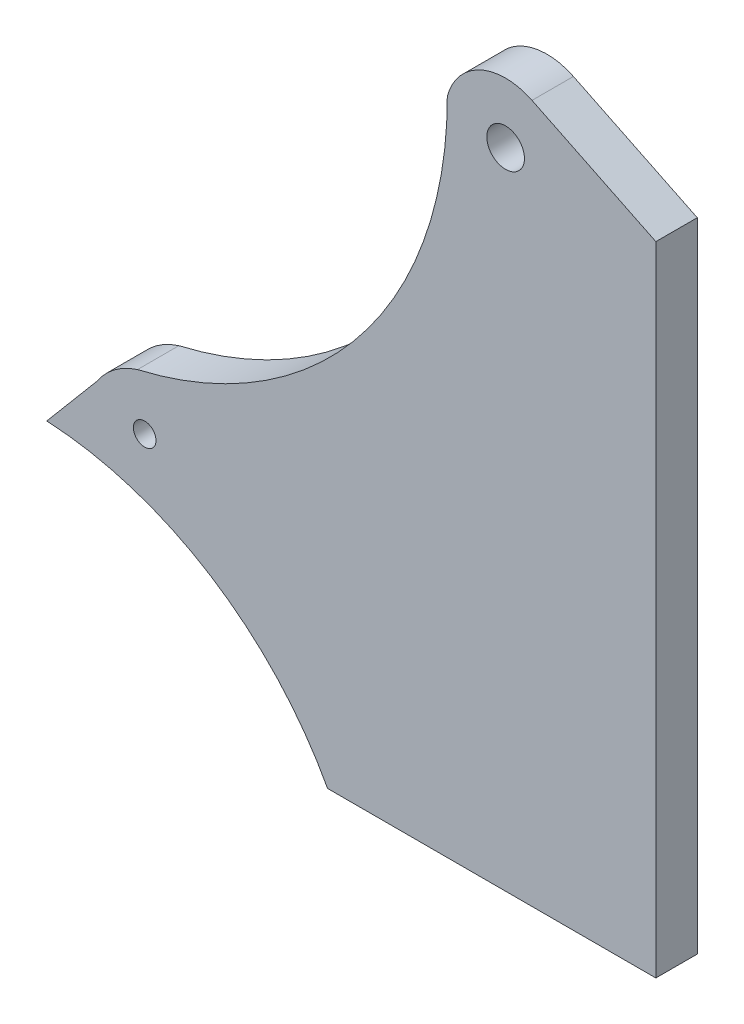
from build123d import *

# Parameters (mm, degrees)
SKETCH1_R           = 25
SKETCH1_R_2         = 15
BOSS_EXTRUDE1_DEPTH = 55


with BuildPart() as part:
    # Sketch1 → Boss-Extrude1 (new body)
    with BuildSketch(Plane.XY):
        with BuildLine():
            Line((0, 0), (436, 0))
            Line((436, 0), (436, 847))
            Line((436, 847), (271.520689527, 927.221919862))
            ThreePointArc((271.520689527, 927.221919862), (202.977427959, 927.978702538), (159.009788885, 875.389747989))
            ThreePointArc((159.009788885, 875.389747989), (44.140964675, 543.56321378), (-252.456286899, 355.590433997))
            ThreePointArc((-252.456286899, 355.590433997), (-283.190978989, 339.913558022), (-306.768623817, 314.724663594))
            Line((-306.768623817, 314.724663594), (-372.987704373, 236.21505403))
            ThreePointArc((-372.987704373, 236.21505403), (-155.534588664, 166.992745943), (0, 0))
        make_face()
        with Locations((236.450997784, 855.318396158)):
            Circle(SKETCH1_R, mode=Mode.SUBTRACT)
        with Locations((-242.894848687, 286.21505403)):
            Circle(SKETCH1_R_2, mode=Mode.SUBTRACT)
    extrude(amount=BOSS_EXTRUDE1_DEPTH)


solid = part.part
